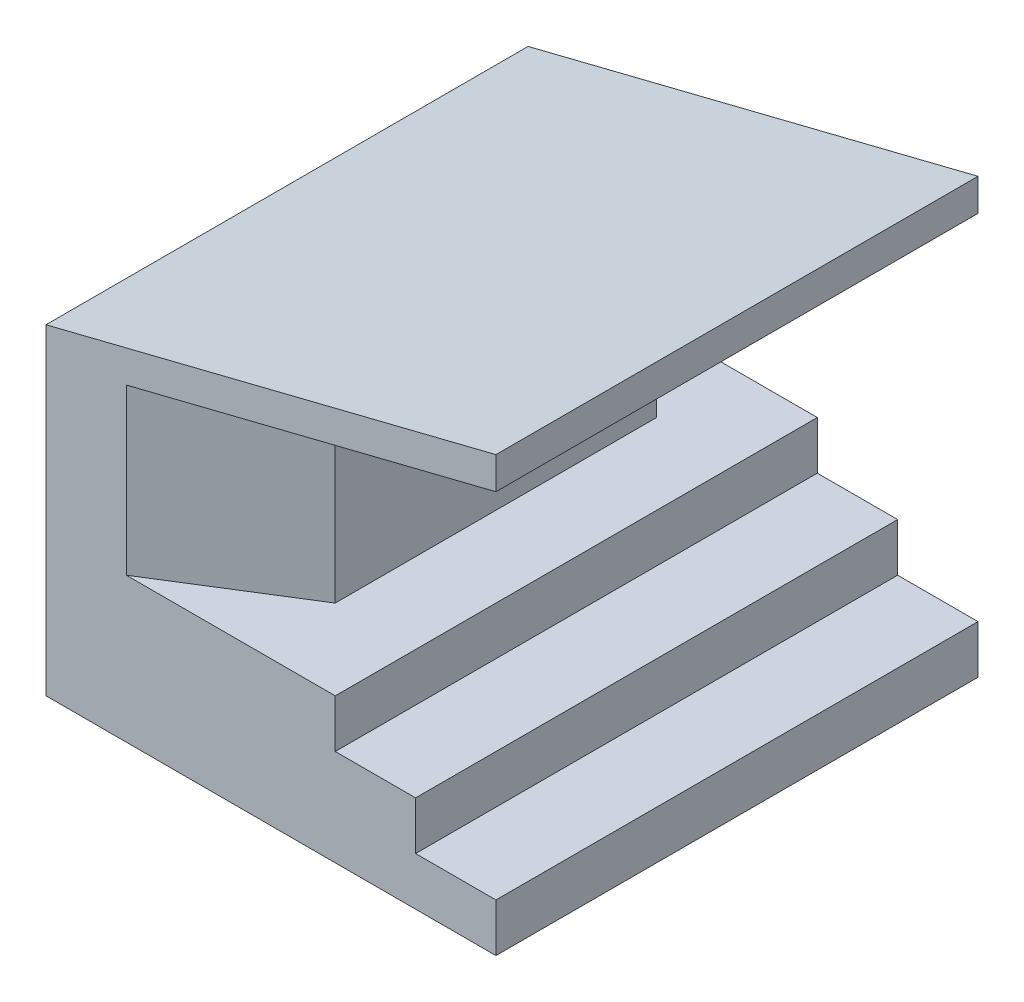
from build123d import *

# Parameters (mm, degrees)
SKETCH1_W      = 140
SKETCH1_H      = 150
EXTRUDE1_DEPTH = 15
EXTRUDE2_DEPTH = 150
EXTRUDE3_REACH = 92


with BuildPart() as part:
    # Sketch1 → Extrude1 (new body)
    with BuildSketch(Plane(origin=(0, 0, 0), x_dir=(1, 0, 0), z_dir=(0, 1, 0))):
        with Locations((-70, 75)):
            Rectangle(SKETCH1_W, SKETCH1_H)
    extrude(amount=EXTRUDE1_DEPTH)

    # Sketch2 → Extrude2 (add)
    with BuildSketch(Plane.XY):
        Polygon((-25, 15), (-25, 30), (-50, 30), (-50, 45), (-115, 45), (-115, 96.25), (0, 125), (0, 135), (-140, 100), (-140, 15), align=None)
    extrude(amount=-EXTRUDE2_DEPTH)

    # Extrude3: up to this plane
    extrude3_end = Plane(origin=(-115, 96.25, -150), z_dir=(0.242535625, -0.9701425, 0))
    # Sketch3 → Extrude3 (add, up to the surface)
    with BuildSketch(Plane(origin=(0, 45, 0), x_dir=(1, 0, 0), z_dir=(0, 1, 0)), mode=Mode.PRIVATE) as extrude3_sk1:
        Polygon((-115, 150), (-75, 125), (-75, 25), (-115, 0), align=None)
    extrude3_tool1 = split(extrude(extrude3_sk1.sketch, amount=EXTRUDE3_REACH, mode=Mode.PRIVATE), bisect_by=extrude3_end, keep=Keep.BOTH, mode=Mode.PRIVATE)
    add(extrude3_tool1.solids().sort_by_distance((-96.333333, 45, -75))[0])


solid = part.part
